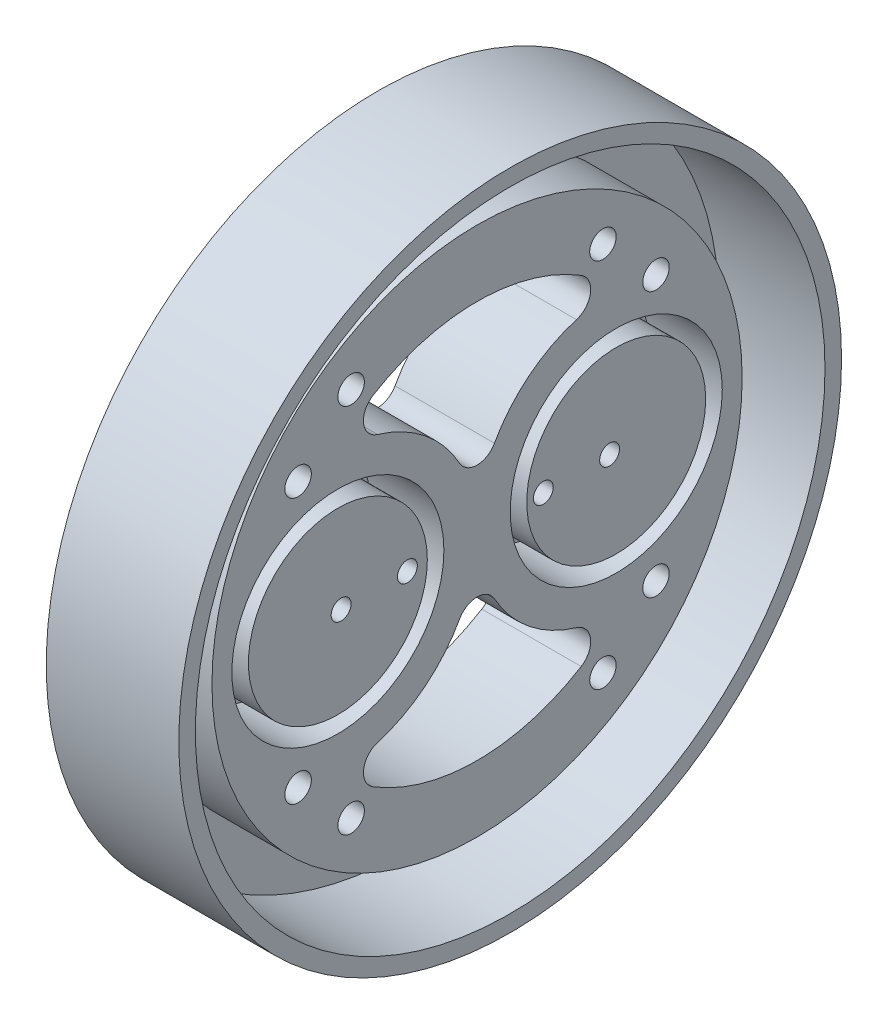
from build123d import *

# Parameters (mm, degrees)
SKETCH1_R           = 50
SKETCH1_R_2         = 47.5
BOSS_EXTRUDE1_DEPTH = 20
SKETCH1_3_R         = 50
BOSS_EXTRUDE2_DEPTH = 4
SKETCH1_4_R         = 40
SKETCH1_4_R_2       = 16
SKETCH1_4_R_3       = 13.5
BOSS_EXTRUDE3_DEPTH = 15
SKETCH2_R           = 2
SKETCH2_R_2         = 1.5
CUT_EXTRUDE1_DEPTH  = 73.284161474


with BuildPart() as part:
    # Sketch1 → Boss-Extrude1 (new body)
    with BuildSketch(Plane(origin=(0, 0, 0), x_dir=(0, 0, -1), z_dir=(1, 0, 0))):
        Circle(SKETCH1_R)
        Circle(SKETCH1_R_2, mode=Mode.SUBTRACT)
    extrude(amount=BOSS_EXTRUDE1_DEPTH)

    # Sketch1_3 → Boss-Extrude2 (add)
    with BuildSketch(Plane(origin=(0, 0, 0), x_dir=(0, 0, -1), z_dir=(1, 0, 0))):
        Circle(SKETCH1_3_R)
        with BuildLine():
            ThreePointArc((15.714285714, 25.5550626), (17.117237545, 22.608325942), (15, 20.124611797))
            ThreePointArc((15, 20.124611797), (7.83467626, 16.36075337), (2.625, 10.166581284))
            ThreePointArc((2.625, 10.166581284), (0, 8.618950039), (-2.625, 10.166581284))
            ThreePointArc((-2.625, 10.166581284), (-7.83467626, 16.36075337), (-15, 20.124611797))
            ThreePointArc((-15, 20.124611797), (-17.117237545, 22.608325942), (-15.714285714, 25.5550626))
            ThreePointArc((-15.714285714, 25.5550626), (0, 30), (15.714285714, 25.5550626))
        make_face(mode=Mode.SUBTRACT)
        with BuildLine():
            ThreePointArc((-15.714285714, -25.5550626), (-17.117237545, -22.608325942), (-15, -20.124611797))
            ThreePointArc((-15, -20.124611797), (-7.83467626, -16.36075337), (-2.625, -10.166581284))
            ThreePointArc((-2.625, -10.166581284), (0, -8.618950039), (2.625, -10.166581284))
            ThreePointArc((2.625, -10.166581284), (7.83467626, -16.36075337), (15, -20.124611797))
            ThreePointArc((15, -20.124611797), (17.117237545, -22.608325942), (15.714285714, -25.5550626))
            ThreePointArc((15.714285714, -25.5550626), (0, -30), (-15.714285714, -25.5550626))
        make_face(mode=Mode.SUBTRACT)
    extrude(amount=BOSS_EXTRUDE2_DEPTH)

    # Sketch1_4 → Boss-Extrude3 (add)
    # profile 1 of 3: a face of its own
    with BuildSketch(Plane(origin=(0, 0, 0), x_dir=(0, 0, -1), z_dir=(1, 0, 0))):
        Circle(SKETCH1_4_R)
        with BuildLine():
            ThreePointArc((-15.714285714, -25.5550626), (-17.117237545, -22.608325942), (-15, -20.124611797))
            ThreePointArc((-15, -20.124611797), (-7.83467626, -16.36075337), (-2.625, -10.166581284))
            ThreePointArc((-2.625, -10.166581284), (0, -8.618950039), (2.625, -10.166581284))
            ThreePointArc((2.625, -10.166581284), (7.83467626, -16.36075337), (15, -20.124611797))
            ThreePointArc((15, -20.124611797), (17.117237545, -22.608325942), (15.714285714, -25.5550626))
            ThreePointArc((15.714285714, -25.5550626), (0, -30), (-15.714285714, -25.5550626))
        make_face(mode=Mode.SUBTRACT)
        with Locations((-21, 0)):
            Circle(SKETCH1_4_R_2, mode=Mode.SUBTRACT)
        with Locations((21, 0)):
            Circle(SKETCH1_4_R_2, mode=Mode.SUBTRACT)
        with BuildLine():
            ThreePointArc((-15.714285714, 25.5550626), (0, 30), (15.714285714, 25.5550626))
            ThreePointArc((15.714285714, 25.5550626), (17.117237545, 22.608325942), (15, 20.124611797))
            ThreePointArc((15, 20.124611797), (7.83467626, 16.36075337), (2.625, 10.166581284))
            ThreePointArc((2.625, 10.166581284), (0, 8.618950039), (-2.625, 10.166581284))
            ThreePointArc((-2.625, 10.166581284), (-7.83467626, 16.36075337), (-15, 20.124611797))
            ThreePointArc((-15, 20.124611797), (-17.117237545, 22.608325942), (-15.714285714, 25.5550626))
        make_face(mode=Mode.SUBTRACT)
    # profile 2 of 3: a face of its own
    with BuildSketch(Plane(origin=(0, 0, 0), x_dir=(0, 0, -1), z_dir=(1, 0, 0))):
        with Locations((-21, 0)):
            Circle(SKETCH1_4_R_3)
    # profile 3 of 3: a face of its own
    with BuildSketch(Plane(origin=(0, 0, 0), x_dir=(0, 0, -1), z_dir=(1, 0, 0))):
        with Locations((21, 0)):
            Circle(SKETCH1_4_R_3)
    extrude(amount=BOSS_EXTRUDE3_DEPTH)

    # Sketch2 → Cut-Extrude1 (cut, through all)
    with BuildSketch(Plane(origin=(15, 0, 0), x_dir=(0, 0, -1), z_dir=(1, 0, 0))):
        with Locations((-27, -20)):
            Circle(SKETCH2_R)
        with Locations((-19, -28)):
            Circle(SKETCH2_R)
        with Locations((-20.508, 0)):
            Circle(SKETCH2_R_2)
        with Locations((-10.508, 0)):
            Circle(SKETCH2_R_2)
        with Locations((10, 0)):
            Circle(SKETCH2_R_2)
        with Locations((20, 0)):
            Circle(SKETCH2_R_2)
        with Locations((19, -28)):
            Circle(SKETCH2_R)
        with Locations((27, -20)):
            Circle(SKETCH2_R)
        with Locations((27, 20)):
            Circle(SKETCH2_R)
        with Locations((19, 28)):
            Circle(SKETCH2_R)
        with Locations((-19, 28)):
            Circle(SKETCH2_R)
        with Locations((-27, 20)):
            Circle(SKETCH2_R)
    extrude(amount=-CUT_EXTRUDE1_DEPTH, mode=Mode.SUBTRACT)


solid = part.part
